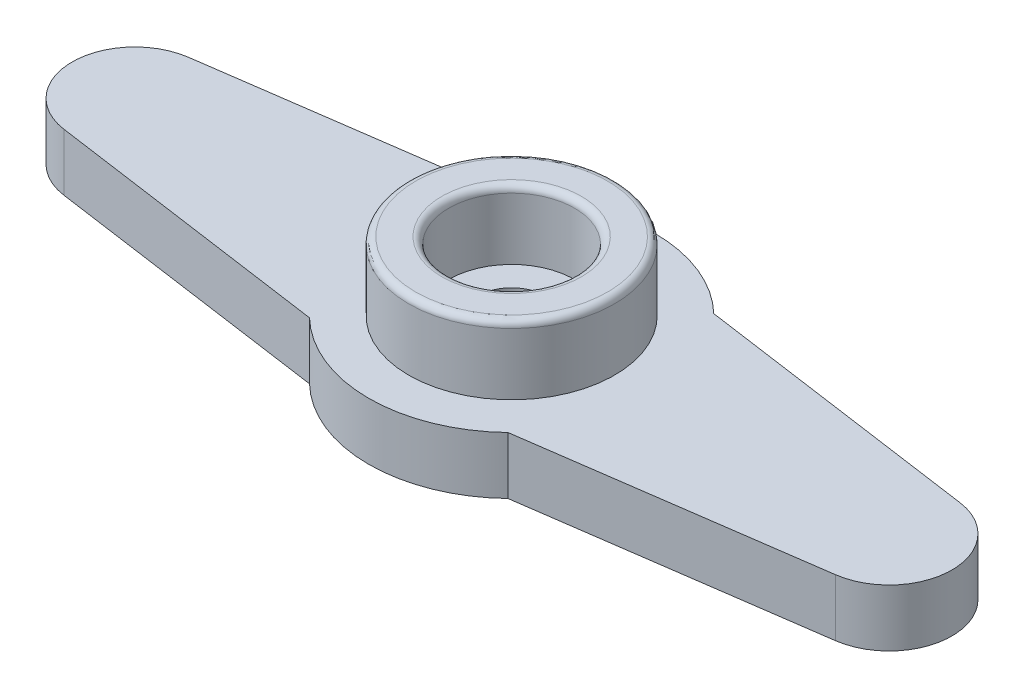
from build123d import *

# Parameters (mm, degrees)
SALIENTE_EXTRUIR1_DEPTH = 2.5
CROQUIS2_R              = 4.5
CROQUIS2_R_2            = 2.75
SALIENTE_EXTRUIR2_DEPTH = 3
CORTAR_EXTRUIR1_REACH   = 7.5
CROQUIS3_R              = 1.5
CROQUIS4_R              = 2.8
CORTAR_EXTRUIR2_DEPTH   = 1
CROQUIS5_R              = 4.5
CROQUIS5_R_2            = 3.5
CORTAR_EXTRUIR3_DEPTH   = 0.5
REDONDEO1_R             = 0.3


with BuildPart() as part:
    # Croquis1 → Saliente-Extruir1 (new body)
    with BuildSketch(Plane(origin=(0, 0, 0), x_dir=(1, 0, 0), z_dir=(0, 1, 0))):
        with BuildLine():
            Line((16.885625022, 2.722828188), (4.337337893, 4.5))
            ThreePointArc((4.337337893, 4.5), (-0.003678449, 6.249998918), (-4.342631854, 4.494891387))
            Line((-4.342631854, 4.494891387), (-16.854847994, 2.722828188))
            ThreePointArc((-16.854847994, 2.722828188), (-19.219222971, 0), (-16.854847994, -2.722828188))
            Line((-16.854847994, -2.722828188), (-4.342631854, -4.494891387))
            ThreePointArc((-4.342631854, -4.494891387), (-0.003678449, -6.249998918), (4.337337893, -4.5))
            Line((4.337337893, -4.5), (16.885625022, -2.722828188))
            ThreePointArc((16.885625022, -2.722828188), (19.25, 0), (16.885625022, 2.722828188))
        make_face()
    extrude(amount=SALIENTE_EXTRUIR1_DEPTH)

    # Croquis2 → Saliente-Extruir2 (add)
    with BuildSketch(Plane(origin=(0, 2.5, 0), x_dir=(1, 0, 0), z_dir=(0, 1, 0))):
        Circle(CROQUIS2_R)
        Circle(CROQUIS2_R_2, mode=Mode.SUBTRACT)
    extrude(amount=SALIENTE_EXTRUIR2_DEPTH)

    # Croquis3 → Cortar-Extruir1 (cut, up to next)
    with BuildSketch(Plane.XZ, mode=Mode.PRIVATE) as cortar_extruir1_sk1:
        Circle(CROQUIS3_R)
    cortar_extruir1_tool1 = extrude(cortar_extruir1_sk1.sketch, amount=-CORTAR_EXTRUIR1_REACH, mode=Mode.PRIVATE) & part.part
    add(cortar_extruir1_tool1.solids().sort_by_distance((0, 0, 0))[0], mode=Mode.SUBTRACT)

    # Croquis4 → Cortar-Extruir2 (cut)
    with BuildSketch(Plane.XZ):
        Circle(CROQUIS4_R)
    extrude(amount=-CORTAR_EXTRUIR2_DEPTH, mode=Mode.SUBTRACT)

    # Croquis5 → Cortar-Extruir3 (cut)
    with BuildSketch(Plane.XZ):
        Circle(CROQUIS5_R)
        Circle(CROQUIS5_R_2, mode=Mode.SUBTRACT)
    extrude(amount=-CORTAR_EXTRUIR3_DEPTH, mode=Mode.SUBTRACT)

    # Redondeo1
    redondeo1_edges = [part.edges().sort_by_distance(p)[0] for p in [
        (-4.5, 5.5, 0),
        (-2.75, 5.5, 0),
        (-2.8, 0, 0),
        (-4.5, 0, 0),
        (-3.5, 0, 0),
    ]]
    fillet(redondeo1_edges, radius=REDONDEO1_R)


solid = part.part
